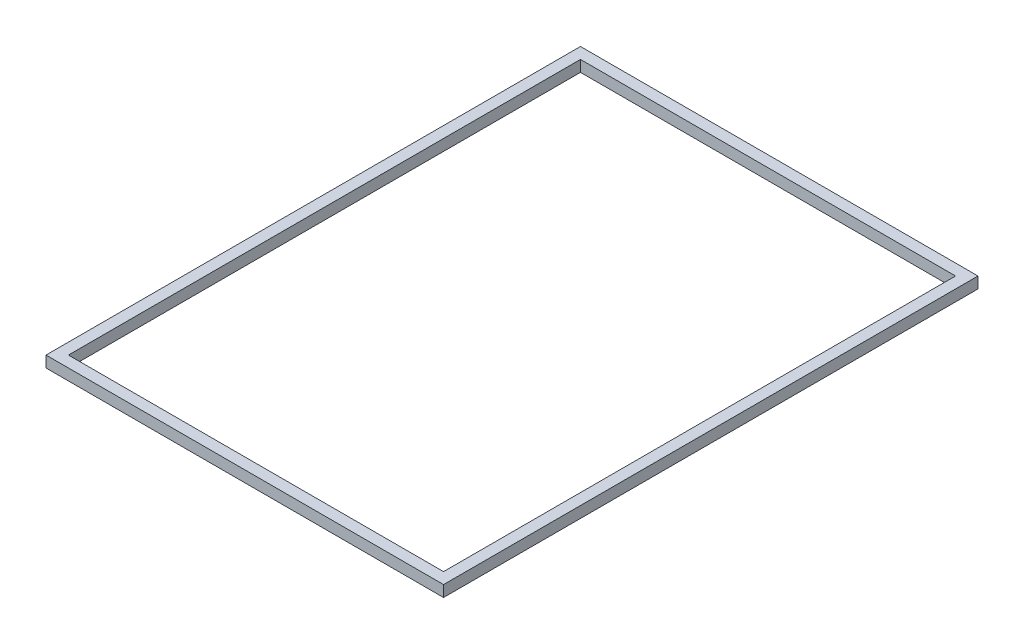
from build123d import *

# Parameters (mm, degrees)
SKETCH2_W   = 25.4
SKETCH2_H   = 25.4
SKETCH2_W_2 = 23
SKETCH2_H_2 = 23


with BuildPart() as part:
    # Sweep1: sweep along a path in Sketch1
    with BuildLine(Plane(origin=(0, 0, 0), x_dir=(1, 0, 0), z_dir=(0, 1, 0))) as sweep1_path:
        Line((-450, 605), (450, 605))
        Line((450, 605), (450, -605))
        Line((450, -605), (-450, -605))
        Line((-450, -605), (-450, 605))
    # Sketch2 → Sweep1 (sweep)
    with BuildSketch(Plane(origin=(0, 0, 0), x_dir=(0, 0, -1), z_dir=(1, 0, 0))):
        with Locations((-592.3, 12.7)):
            Rectangle(SKETCH2_W, SKETCH2_H)
        with Locations((-592.3, 12.7)):
            Rectangle(SKETCH2_W_2, SKETCH2_H_2, mode=Mode.SUBTRACT)
    sweep(path=sweep1_path.line, transition=Transition.RIGHT)


solid = part.part
